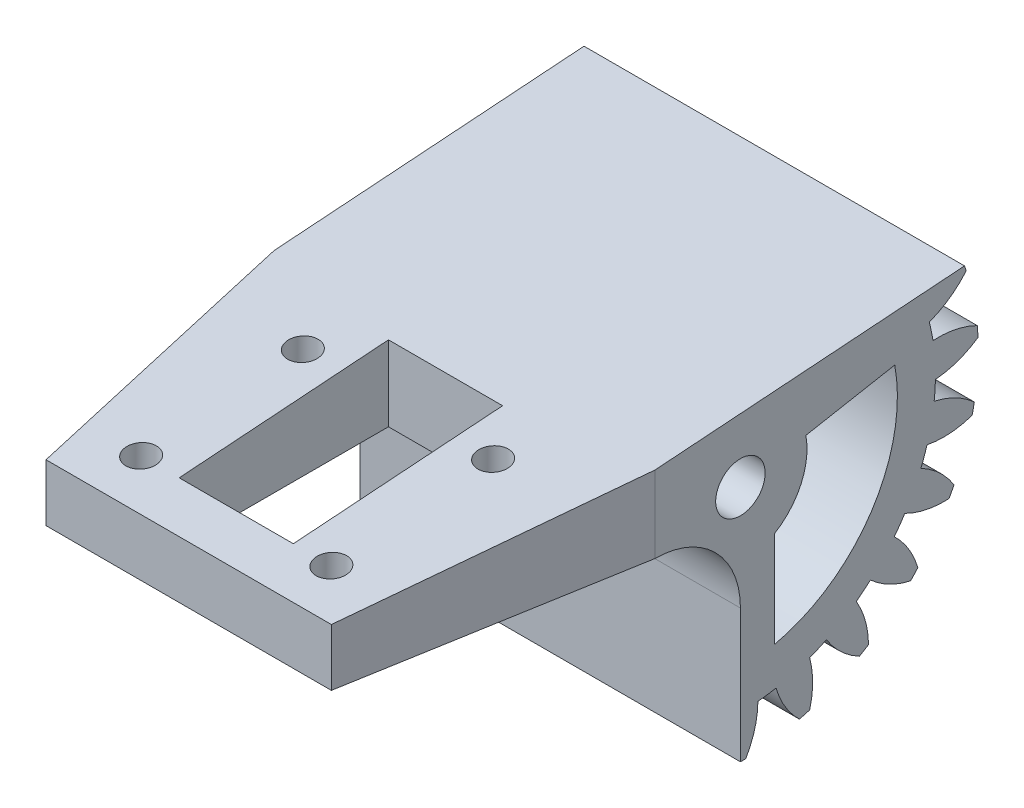
from build123d import *

# Parameters (mm, degrees)
BASPROSKE_W         = 40
BASPROSKE_H         = 25
TOOTHCUT_DEPTH      = 54.38539126
TEETHCUTS_COUNT     = 23
TEETHCUTS_ANGLE     = 344.347826087
BORSKE_R            = 0.4
BORE_DEPTH          = 50.0000508
CUT_EXTRUDE_1_DEPTH = 54.3731118
SKETCH_2_R          = 1.6
CUT_EXTRUDE_2_DEPTH = 54.3731118
EXTRUDE_1_DEPTH     = 40
SKETCH_5_R          = 1.6
CUT_EXTRUDE_3_DEPTH = 61.166132826
CUT_EXTRUDE_4_DEPTH = 61.571969914
SKETCH_7_W          = 12
SKETCH_7_H          = 22
CUT_EXTRUDE_5_DEPTH = 61.166132826
SKETCH_8_R          = 2.6
CUT_EXTRUDE_6_DEPTH = 61.571969914
SKETCH_10_R         = 1.6
SKETCH_10_W         = 12
SKETCH_10_H         = 22
CUT_EXTRUDE_7_DEPTH = 61.166132826
CUT_EXTRUDE_9_DEPTH = 60.774271549


with BuildPart() as part:
    # BasProSke → Base-Revolve (revolve)
    with BuildSketch(Plane(origin=(0, 0, 0), x_dir=(1, 0, 0), z_dir=(0, 1, 0)), mode=Mode.PRIVATE) as base_revolve_sk:
        with Locations((20, 12.5)):
            Rectangle(BASPROSKE_W, BASPROSKE_H)
    revolve(base_revolve_sk.sketch.rotate(Axis((-10, 0, 0), (1, 0, 0)), 180), axis=Axis((-10, 0, 0), (1, 0, 0)))

    # TooCutSke → ToothCut (cut, through all)
    with BuildSketch(Plane(origin=(0, 0, 0), x_dir=(0, 0, -1), z_dir=(1, 0, 0))):
        with BuildLine():
            ThreePointArc((0.960248578, 20.47649686), (0, 20.499), (-0.960248578, 20.47649686))
            ThreePointArc((-0.960248578, 20.47649686), (-1.62297083, 22.794554384), (-2.865164893, 24.860842208))
            ThreePointArc((-2.865164893, 24.860842208), (0, 25.0254), (2.865164893, 24.860842208))
            ThreePointArc((2.865164893, 24.860842208), (1.62297083, 22.794554384), (0.960248578, 20.47649686))
        make_face()
    toothcut = extrude(amount=TOOTHCUT_DEPTH, mode=Mode.SUBTRACT)

    # TeethCuts: ToothCut ×23 about axis
    teethcuts_axis = Axis((-10, 0, 0), (1, 0, 0))
    for i in range(1, TEETHCUTS_COUNT):
        add(toothcut.rotate(teethcuts_axis, i * TEETHCUTS_ANGLE / (TEETHCUTS_COUNT - 1)), mode=Mode.SUBTRACT)

    # BorSke → Bore (cut, symmetric)
    with BuildSketch(Plane(origin=(0, 0, 0), x_dir=(0, 0, -1), z_dir=(1, 0, 0))):
        with Locations(Location((0, 0, 0), (0, 0, 180))):
            Circle(BORSKE_R)
    extrude(amount=BORE_DEPTH, both=True, mode=Mode.SUBTRACT)

    # 草图1 → 切除-拉伸1 (cut, through all)
    with BuildSketch(Plane(origin=(40, 0, 0), x_dir=(0, 0, -1), z_dir=(1, 0, 0))):
        Polygon((0, 0), (0, -25), (-13.134994366, -31.325673685), (-39.860156169, 4.307875386), (-10.07883231, 32.723680029), (33.144547114, 17.371523179), (23.556523053, 8.371990304), align=None)
    extrude(amount=-CUT_EXTRUDE_1_DEPTH, mode=Mode.SUBTRACT)

    # 草图2 → 切除-拉伸2 (cut, through all)
    with BuildSketch(Plane.ZY):
        Circle(SKETCH_2_R)
    extrude(amount=-CUT_EXTRUDE_2_DEPTH, mode=Mode.SUBTRACT)

    # 草图4 → 凸台-拉伸1 (add)
    with BuildSketch(Plane(origin=(40, 0, 0), x_dir=(0, 0, -1), z_dir=(1, 0, 0))):
        with BuildLine():
            Line((0, -4), (0, -11))
            ThreePointArc((0, -11), (-2.636038969, -4.636038969), (-9, -2))
            Line((-9, -2), (-37.99952025, -2))
            Line((-37.99952025, -2), (-37.99952025, 4))
            Line((-37.99952025, 4), (23.556523053, 8.371990304))
            Line((23.556523053, 8.371990304), (1.507617475, 0.535807379))
            ThreePointArc((1.507617475, 0.535807379), (-1.307151829, 0.922688515), (0, -1.6))
            Line((0, -1.6), (0, -4))
        make_face()
    extrude(amount=-EXTRUDE_1_DEPTH)

    # 草图5 → 切除-拉伸3 (cut, through all)
    with BuildSketch(Plane.XZ.offset(1)):
        with Locations(Location((30, 15.99952025, 0), (0, 0, 270))):
            Circle(SKETCH_5_R)
        with Locations(Location((30, 32.99952025, 0), (0, 0, 270))):
            Circle(SKETCH_5_R)
        with Locations(Location((10, 32.99952025, 0), (0, 0, 90))):
            Circle(SKETCH_5_R)
        with Locations(Location((10, 15.99952025, 0), (0, 0, 90))):
            Circle(SKETCH_5_R)
    extrude(amount=-CUT_EXTRUDE_3_DEPTH, mode=Mode.SUBTRACT)

    # 草图6 → 切除-拉伸4 (cut, through all)
    with BuildSketch(Plane.ZY):
        with BuildLine():
            Line((-6.882467579, 1.277356656), (-16.222959293, 3.010912119))
            ThreePointArc((-16.222959293, 3.010912119), (-13.76317845, -9.100819686), (-3.581631723, -16.106579842))
            Line((-3.581631723, -16.106579842), (-3.581631723, -6.014309121))
            ThreePointArc((-3.581631723, -6.014309121), (-6.377024463, -2.886790432), (-6.882467579, 1.277356656))
        make_face()
    extrude(amount=-CUT_EXTRUDE_4_DEPTH, mode=Mode.SUBTRACT)

    # 草图7 → 切除-拉伸5 (cut, through all)
    with BuildSketch(Plane.XZ.offset(1)):
        with Locations((20, 21.99952025)):
            Rectangle(SKETCH_7_W, SKETCH_7_H)
    extrude(amount=-CUT_EXTRUDE_5_DEPTH, mode=Mode.SUBTRACT)

    # 草图8 → 切除-拉伸6 (cut, through all)
    with BuildSketch(Plane(origin=(40, 0, 0), x_dir=(0, 0, -1), z_dir=(1, 0, 0))):
        Circle(SKETCH_8_R)
    extrude(amount=-CUT_EXTRUDE_6_DEPTH, mode=Mode.SUBTRACT)

    # 草图10 → 切除-拉伸7 (cut, through all)
    with BuildSketch(Plane(origin=(0, -1, 0), x_dir=(1, 0, 0), z_dir=(0, 1, 0))):
        with Locations(Location((10, -15.99952025, 0), (0, 0, 90))):
            Circle(SKETCH_10_R)
        with Locations(Location((10, -32.99952025, 0), (0, 0, 90))):
            Circle(SKETCH_10_R)
        with Locations(Location((30, -15.99952025, 0), (0, 0, 90))):
            Circle(SKETCH_10_R)
        with Locations(Location((30, -32.99952025, 0), (0, 0, 90))):
            Circle(SKETCH_10_R)
        with Locations((20, -21.99952025)):
            Rectangle(SKETCH_10_W, SKETCH_10_H)
    extrude(amount=-CUT_EXTRUDE_7_DEPTH, mode=Mode.SUBTRACT)

    # 草图12 → 切除-拉伸9 (cut, through all)
    with BuildSketch(Plane.XZ.offset(2)):
        Polygon((5, 37.99952025), (0, 9), (0, 37.99952025), align=None)
        Polygon((35, 37.99952025), (40, 9), (40, 37.99952025), align=None)
    extrude(amount=-CUT_EXTRUDE_9_DEPTH, mode=Mode.SUBTRACT)


solid = part.part
